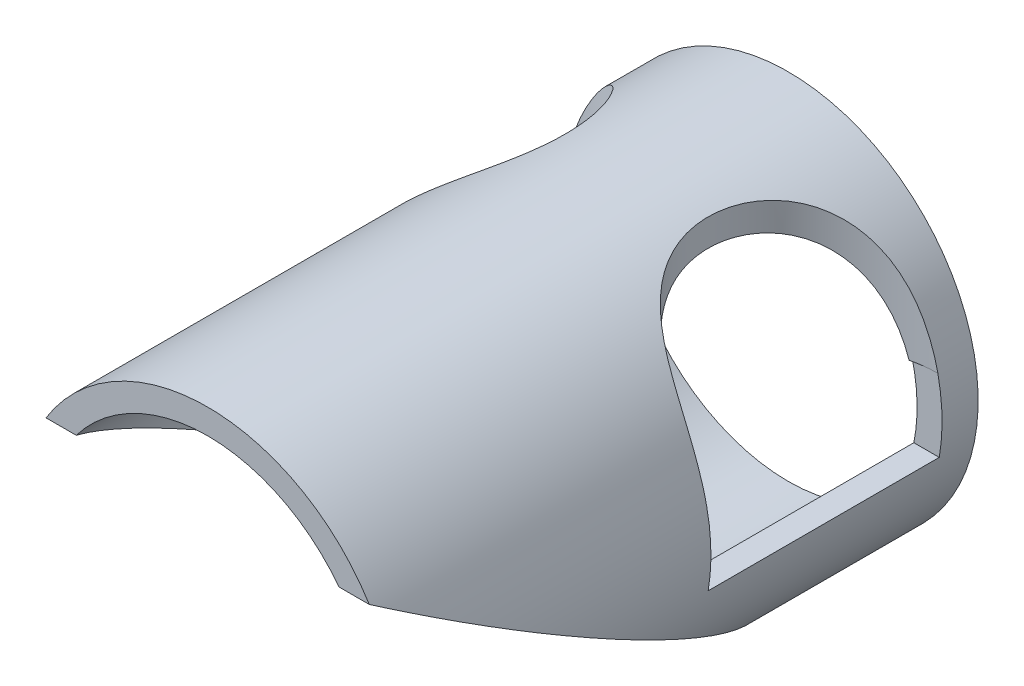
from build123d import *

# Parameters (mm, degrees)
SKETCH1_R               = 83.4771
SKETCH1_R_2             = 72.5043
BOSS_EXTRUDE1_DEPTH     = 65.0875
SKETCH3_W               = 101.6
SKETCH3_H               = 28.575
CUT_EXTRUDE2_DEPTH      = 84.4771
CUT_EXTRUDE2_DEPTH_BACK = 84.4771
SKETCH4_R               = 50.8
CUT_EXTRUDE3_DEPTH      = 98.7646
SKETCH6_W               = 101.6
SKETCH6_H               = 3.175
CUT_EXTRUDE4_DEPTH      = 84.4771001
CUT_EXTRUDE4_DEPTH_BACK = 84.4771001
SKETCH9_R               = 83.4771
SKETCH9_R_2             = 72.5043
BOSS_EXTRUDE2_DEPTH     = 508
SKETCH13_W              = 203.2
SKETCH13_H              = 2032
CUT_EXTRUDE7_DEPTH      = 762
SKETCH15_W              = 203.2
SKETCH15_H              = 203.2
CUT_EXTRUDE9_DEPTH      = 203.2
SKETCH16_R              = 83.4771
SKETCH16_R_2            = 72.5043
BOSS_EXTRUDE3_DEPTH     = 12.7


with BuildPart() as part:
    # Sketch1 → Boss-Extrude1 (new body, symmetric)
    with BuildSketch(Plane.XY):
        Circle(SKETCH1_R)
        Circle(SKETCH1_R_2, mode=Mode.SUBTRACT)
    extrude(amount=BOSS_EXTRUDE1_DEPTH, both=True)

    # Sketch3 → Cut-Extrude2 (cut, two sides)
    with BuildSketch(Plane(origin=(0, 0, 0), x_dir=(0, 0, -1), z_dir=(1, 0, 0))) as cut_extrude2_sk:
        with Locations((11.1125, 0)):
            Rectangle(SKETCH3_W, SKETCH3_H)
    extrude(amount=CUT_EXTRUDE2_DEPTH, mode=Mode.SUBTRACT)
    extrude(cut_extrude2_sk.sketch, amount=-CUT_EXTRUDE2_DEPTH_BACK, mode=Mode.SUBTRACT)

    # Sketch4 → Cut-Extrude3 (cut, through all)
    with BuildSketch(Plane(origin=(0, -14.2875, 0), x_dir=(1, 0, 0), z_dir=(0, 1, 0))):
        with Locations((-82.245325509, 11.1125)):
            Circle(SKETCH4_R)
        with Locations((82.245325509, 11.1125)):
            Circle(SKETCH4_R)
    extrude(amount=CUT_EXTRUDE3_DEPTH, mode=Mode.SUBTRACT)

    # Sketch6 → Cut-Extrude4 (cut, two sides)
    with BuildSketch(Plane(origin=(0, 0, 0), x_dir=(0, 0, -1), z_dir=(1, 0, 0))) as cut_extrude4_sk:
        with Locations((11.1125, 15.875)):
            Rectangle(SKETCH6_W, SKETCH6_H)
    extrude(amount=CUT_EXTRUDE4_DEPTH, mode=Mode.SUBTRACT)
    extrude(cut_extrude4_sk.sketch, amount=-CUT_EXTRUDE4_DEPTH_BACK, mode=Mode.SUBTRACT)

    # Sketch9 → Boss-Extrude2 (add)
    with BuildSketch(Plane.XY.offset(65.0875)):
        Circle(SKETCH9_R)
        Circle(SKETCH9_R_2, mode=Mode.SUBTRACT)
    extrude(amount=BOSS_EXTRUDE2_DEPTH)

    # Sketch13 → Cut-Extrude7 (cut)
    with BuildSketch(Plane(origin=(0, -43.994090512, 25.4), x_dir=(-1, 0, 0), z_dir=(0, 0.866025404, -0.5))):
        with Locations((0, 87.988181024)):
            Rectangle(SKETCH13_W, SKETCH13_H)
    extrude(amount=-CUT_EXTRUDE7_DEPTH, mode=Mode.SUBTRACT)

    # Sketch15 → Cut-Extrude9 (cut)
    with BuildSketch(Plane(origin=(0, 0, 177.4825), x_dir=(-1, 0, 0), z_dir=(0, 0, -1))):
        Rectangle(SKETCH15_W, SKETCH15_H)
    extrude(amount=-CUT_EXTRUDE9_DEPTH, mode=Mode.SUBTRACT)

    # Sketch16 → Boss-Extrude3 (add)
    with BuildSketch(Plane(origin=(0, 0, -65.0875), x_dir=(-1, 0, 0), z_dir=(0, 0, -1))):
        Circle(SKETCH16_R)
        Circle(SKETCH16_R_2, mode=Mode.SUBTRACT)
    extrude(amount=BOSS_EXTRUDE3_DEPTH)


solid = part.part
